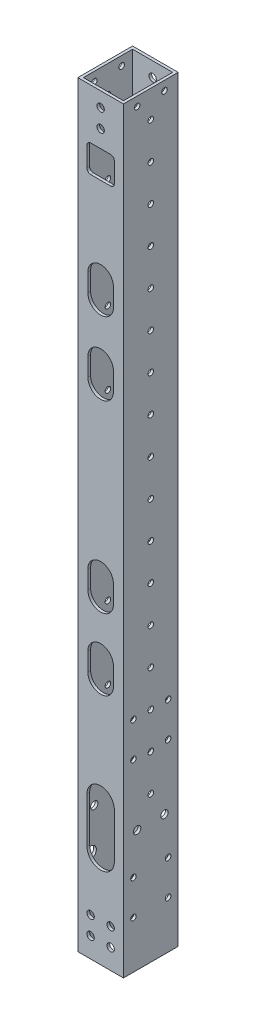
from build123d import *

# Parameters (mm, degrees)
SKETCH_2_W                = 25
SKETCH_2_H                = 30
EXTRUDE_1_DEPTH           = 207.5
SKETCH_3_W                = 22
SKETCH_3_H                = 27
CUT_EXTRUDE_1_DEPTH       = 208.5
CUT_EXTRUDE_1_DEPTH_BACK  = 208.5
SKETCH_4_R                = 1.525
CUT_EXTRUDE_2_DEPTH       = 1
CUT_EXTRUDE_2_DEPTH_BACK  = 26
CUT_EXTRUDE_3_REACH       = 27
SKETCH_5_R                = 3.15
SKETCH_6_R                = 2.025
CUT_EXTRUDE_4_DEPTH       = 31
SKETCH_7_R                = 2.025
CUT_EXTRUDE_5_DEPTH       = 1
CUT_EXTRUDE_5_DEPTH_BACK  = 31
CUT_EXTRUDE_START         = -30
SKETCH_8_R                = 4
CUT_EXTRUDE_7_DEPTH       = 1.5
SKETCH_9_R                = 1.525
CUT_EXTRUDE_8_DEPTH       = 26
SKETCH_10_R               = 3
CUT_EXTRUDE_9_DEPTH       = 5
SKETCH_11_R               = 1.525
CUT_EXTRUDE_10_DEPTH      = 1
CUT_EXTRUDE_10_DEPTH_BACK = 26
SKETCH_12_R               = 2.025
CUT_EXTRUDE_11_DEPTH      = 1
CUT_EXTRUDE_11_DEPTH_BACK = 26
CUT_EXTRUDE_12_DEPTH      = 5
PATTERN_LINEAR_1_COUNT    = 7
PATTERN_LINEAR_1_PITCH    = 47
CUT_EXTRUDE_13_DEPTH      = 1
CUT_EXTRUDE_13_DEPTH_BACK = 31
CUT_EXTRUDE_14_DEPTH      = 29.5
CUT_EXTRUDE_14_DEPTH_BACK = 2.5
CUT_EXTRUDE_15_DEPTH      = 10
CUT_EXTRUDE_START_2       = -26
SKETCH_18_R               = 1.525
CUT_EXTRUDE_16_DEPTH      = 27
PATTERN_LINEAR_2_COUNT    = 17
PATTERN_LINEAR_2_PITCH    = 20


with BuildPart() as part:
    # 草图2 → 凸台-拉伸1 (new body, symmetric)
    with BuildSketch(Plane(origin=(0, 0, 0), x_dir=(1, 0, 0), z_dir=(0, 1, 0))):
        Rectangle(SKETCH_2_W, SKETCH_2_H)
    extrude(amount=EXTRUDE_1_DEPTH, both=True)

    # 草图3 → 切除-拉伸1 (cut, two sides)
    with BuildSketch(Plane(origin=(0, 0, 0), x_dir=(1, 0, 0), z_dir=(0, 1, 0))) as cut_extrude_1_sk:
        Rectangle(SKETCH_3_W, SKETCH_3_H)
    extrude(amount=CUT_EXTRUDE_1_DEPTH, mode=Mode.SUBTRACT)
    extrude(cut_extrude_1_sk.sketch, amount=-CUT_EXTRUDE_1_DEPTH_BACK, mode=Mode.SUBTRACT)

    # 草图4 → 切除-拉伸2 (cut, two sides)
    with BuildSketch(Plane.ZY.offset(12.5)) as cut_extrude_2_sk:
        with Locations((-9.5, -162.5)):
            Circle(SKETCH_4_R)
        with Locations((9.5, -162.5)):
            Circle(SKETCH_4_R)
        with Locations((9.5, -181.5)):
            Circle(SKETCH_4_R)
        with Locations((-9.5, -181.5)):
            Circle(SKETCH_4_R)
    extrude(amount=CUT_EXTRUDE_2_DEPTH, mode=Mode.SUBTRACT)
    extrude(cut_extrude_2_sk.sketch, amount=-CUT_EXTRUDE_2_DEPTH_BACK, mode=Mode.SUBTRACT)

    # 草图5 → 切除-拉伸3 (cut, up to next)
    with BuildSketch(Plane.ZY.offset(12.5), mode=Mode.PRIVATE) as cut_extrude_3_sk1:
        with Locations((-9.5, -162.5)):
            Circle(SKETCH_5_R)
    cut_extrude_3_tool1 = extrude(cut_extrude_3_sk1.sketch, amount=-CUT_EXTRUDE_3_REACH, mode=Mode.PRIVATE) & part.part
    add(cut_extrude_3_tool1.solids().sort_by_distance((-12.5, -162.5, -9.5))[0], mode=Mode.SUBTRACT)
    # 草图5 → 切除-拉伸3 (cut, up to next)
    with BuildSketch(Plane.ZY.offset(12.5), mode=Mode.PRIVATE) as cut_extrude_3_sk2:
        with Locations((-9.5, -181.5)):
            Circle(SKETCH_5_R)
    cut_extrude_3_tool2 = extrude(cut_extrude_3_sk2.sketch, amount=-CUT_EXTRUDE_3_REACH, mode=Mode.PRIVATE) & part.part
    add(cut_extrude_3_tool2.solids().sort_by_distance((-12.5, -181.5, -9.5))[0], mode=Mode.SUBTRACT)
    # 草图5 → 切除-拉伸3 (cut, up to next)
    with BuildSketch(Plane.ZY.offset(12.5), mode=Mode.PRIVATE) as cut_extrude_3_sk3:
        with Locations((9.5, -162.5)):
            Circle(SKETCH_5_R)
    cut_extrude_3_tool3 = extrude(cut_extrude_3_sk3.sketch, amount=-CUT_EXTRUDE_3_REACH, mode=Mode.PRIVATE) & part.part
    add(cut_extrude_3_tool3.solids().sort_by_distance((-12.5, -162.5, 9.5))[0], mode=Mode.SUBTRACT)
    # 草图5 → 切除-拉伸3 (cut, up to next)
    with BuildSketch(Plane.ZY.offset(12.5), mode=Mode.PRIVATE) as cut_extrude_3_sk4:
        with Locations((9.5, -181.5)):
            Circle(SKETCH_5_R)
    cut_extrude_3_tool4 = extrude(cut_extrude_3_sk4.sketch, amount=-CUT_EXTRUDE_3_REACH, mode=Mode.PRIVATE) & part.part
    add(cut_extrude_3_tool4.solids().sort_by_distance((-12.5, -181.5, 9.5))[0], mode=Mode.SUBTRACT)

    # 草图6 → 切除-拉伸4 (cut, through all)
    with BuildSketch(Plane(origin=(0, 0, -15), x_dir=(-1, 0, 0), z_dir=(0, 0, -1))):
        with Locations((0, 199.5)):
            Circle(SKETCH_6_R)
        with Locations((0, 189.5)):
            Circle(SKETCH_6_R)
    extrude(amount=-CUT_EXTRUDE_4_DEPTH, mode=Mode.SUBTRACT)

    # 草图7 → 切除-拉伸5 (cut, two sides)
    with BuildSketch(Plane(origin=(0, 0, -15), x_dir=(-1, 0, 0), z_dir=(0, 0, -1))) as cut_extrude_5_sk:
        with Locations((5.5, -186.5)):
            Circle(SKETCH_7_R)
        with Locations((5.5, -196.5)):
            Circle(SKETCH_7_R)
        with Locations((-5.5, -196.5)):
            Circle(SKETCH_7_R)
        with Locations((-5.5, -186.5)):
            Circle(SKETCH_7_R)
    extrude(amount=CUT_EXTRUDE_5_DEPTH, mode=Mode.SUBTRACT)
    extrude(cut_extrude_5_sk.sketch, amount=-CUT_EXTRUDE_5_DEPTH_BACK, mode=Mode.SUBTRACT)

    # 草图8 → 切除-拉伸7 (cut)
    with BuildSketch(Plane.XY.offset(15).offset(CUT_EXTRUDE_START)):
        with Locations((-5.5, -186.5)):
            Circle(SKETCH_8_R)
        with Locations((5.5, -186.5)):
            Circle(SKETCH_8_R)
        with Locations((5.5, -196.5)):
            Circle(SKETCH_8_R)
        with Locations((-5.5, -196.5)):
            Circle(SKETCH_8_R)
    extrude(amount=CUT_EXTRUDE_7_DEPTH, mode=Mode.SUBTRACT)

    # 草图9 → 切除-拉伸8 (cut, through all)
    with BuildSketch(Plane.ZY.offset(12.5)):
        with Locations((-9.5, -87.5)):
            Circle(SKETCH_9_R)
        with Locations((-9.5, -106.5)):
            Circle(SKETCH_9_R)
        with Locations((9.5, -87.5)):
            Circle(SKETCH_9_R)
        with Locations((9.5, -106.5)):
            Circle(SKETCH_9_R)
    extrude(amount=-CUT_EXTRUDE_8_DEPTH, mode=Mode.SUBTRACT)

    # 草图10 → 切除-拉伸9 (cut)
    with BuildSketch(Plane.ZY.offset(12.5)):
        with Locations((-9.5, -87.5)):
            Circle(SKETCH_10_R)
        with Locations((-9.5, -106.5)):
            Circle(SKETCH_10_R)
        with Locations((9.5, -87.5)):
            Circle(SKETCH_10_R)
        with Locations((9.5, -106.5)):
            Circle(SKETCH_10_R)
    extrude(amount=-CUT_EXTRUDE_9_DEPTH, mode=Mode.SUBTRACT)

    # 草图11 → 切除-拉伸10 (cut, two sides)
    with BuildSketch(Plane.ZY.offset(12.5)) as cut_extrude_10_sk:
        with Locations((-7.5, 202.5)):
            Circle(SKETCH_11_R)
        with Locations((7.5, 202.5)):
            Circle(SKETCH_11_R)
    extrude(amount=CUT_EXTRUDE_10_DEPTH, mode=Mode.SUBTRACT)
    extrude(cut_extrude_10_sk.sketch, amount=-CUT_EXTRUDE_10_DEPTH_BACK, mode=Mode.SUBTRACT)

    # 草图12 → 切除-拉伸11 (cut, two sides)
    with BuildSketch(Plane.ZY.offset(12.5)) as cut_extrude_11_sk:
        with Locations((-7.5, -141)):
            Circle(SKETCH_12_R)
        with Locations((7.5, -141)):
            Circle(SKETCH_12_R)
    extrude(amount=CUT_EXTRUDE_11_DEPTH, mode=Mode.SUBTRACT)
    extrude(cut_extrude_11_sk.sketch, amount=-CUT_EXTRUDE_11_DEPTH_BACK, mode=Mode.SUBTRACT)

    # 草图13 → 切除-拉伸12 (cut)
    with BuildSketch(Plane(origin=(0, 0, -15), x_dir=(-1, 0, 0), z_dir=(0, 0, -1))):
        with BuildLine():
            Line((-7.5, -155), (-7.5, -130))
            ThreePointArc((-7.5, -130), (0, -122.5), (7.5, -130))
            Line((7.5, -130), (7.5, -155))
            ThreePointArc((7.5, -155), (0, -162.5), (-7.5, -155))
        make_face()
    cut_extrude_12 = extrude(amount=-CUT_EXTRUDE_12_DEPTH, mode=Mode.SUBTRACT)

    # 阵列(线性)1: 切除-拉伸12 ×7
    with Locations(*[(0, i * PATTERN_LINEAR_1_PITCH, 0) for i in range(1, PATTERN_LINEAR_1_COUNT)]):
        add(cut_extrude_12, mode=Mode.SUBTRACT)

    # 草图15 → 切除-拉伸13 (cut, two sides)
    with BuildSketch(Plane(origin=(0, 0, -15), x_dir=(-1, 0, 0), z_dir=(0, 0, -1))) as cut_extrude_13_sk:
        with BuildLine():
            Line((5.5, 165), (-5.5, 165))
            ThreePointArc((-5.5, 165), (-6.914213562, 165.585786438), (-7.5, 167))
            Line((-7.5, 167), (-7.5, 178))
            ThreePointArc((-7.5, 178), (-6.914213562, 179.414213562), (-5.5, 180))
            Line((-5.5, 180), (5.5, 180))
            ThreePointArc((5.5, 180), (6.914213562, 179.414213562), (7.5, 178))
            Line((7.5, 178), (7.5, 167))
            ThreePointArc((7.5, 167), (6.914213562, 165.585786438), (5.5, 165))
        make_face()
    extrude(amount=CUT_EXTRUDE_13_DEPTH, mode=Mode.SUBTRACT)
    extrude(cut_extrude_13_sk.sketch, amount=-CUT_EXTRUDE_13_DEPTH_BACK, mode=Mode.SUBTRACT)

    # 草图16 → 切除-拉伸14 (cut, two sides)
    with BuildSketch(Plane(origin=(0, 0, 13.5), x_dir=(-1, 0, 0), z_dir=(0, 0, -1))) as cut_extrude_14_sk:
        with BuildLine():
            Line((7.5, -155), (7.5, -130))
            ThreePointArc((7.5, -130), (0, -122.5), (-7.5, -130))
            Line((-7.5, -130), (-7.5, -155))
            ThreePointArc((-7.5, -155), (0, -162.5), (7.5, -155))
        make_face()
    extrude(amount=CUT_EXTRUDE_14_DEPTH, mode=Mode.SUBTRACT)
    extrude(cut_extrude_14_sk.sketch, amount=-CUT_EXTRUDE_14_DEPTH_BACK, mode=Mode.SUBTRACT)

    # 草图17 → 切除-拉伸15 (cut)
    with BuildSketch(Plane.XY.offset(15)):
        with BuildLine():
            Line((7, -62), (7, -72))
            ThreePointArc((7, -72), (0, -79), (-7, -72))
            Line((-7, -72), (-7, -62))
            ThreePointArc((-7, -62), (0, -55), (7, -62))
        make_face()
        with BuildLine():
            Line((7, -23), (7, -33))
            ThreePointArc((7, -33), (0, -40), (-7, -33))
            Line((-7, -33), (-7, -23))
            ThreePointArc((-7, -23), (0, -16), (7, -23))
        make_face()
        with BuildLine():
            Line((7, 78), (7, 68))
            ThreePointArc((7, 68), (0, 61), (-7, 68))
            Line((-7, 68), (-7, 78))
            ThreePointArc((-7, 78), (0, 85), (7, 78))
        make_face()
        with BuildLine():
            Line((7, 118), (7, 108))
            ThreePointArc((7, 108), (0, 101), (-7, 108))
            Line((-7, 108), (-7, 118))
            ThreePointArc((-7, 118), (0, 125), (7, 118))
        make_face()
    extrude(amount=-CUT_EXTRUDE_15_DEPTH, mode=Mode.SUBTRACT)

    # 草图18 → 切除-拉伸16 (cut)
    with BuildSketch(Plane.ZY.offset(12.5).offset(CUT_EXTRUDE_START_2)):
        with Locations((0, -127.5)):
            Circle(SKETCH_18_R)
    cut_extrude_16 = extrude(amount=CUT_EXTRUDE_16_DEPTH, mode=Mode.SUBTRACT)

    # 阵列(线性)2: 切除-拉伸16 ×17
    with Locations(*[(0, i * PATTERN_LINEAR_2_PITCH, 0) for i in range(1, PATTERN_LINEAR_2_COUNT)]):
        add(cut_extrude_16, mode=Mode.SUBTRACT)


solid = part.part
